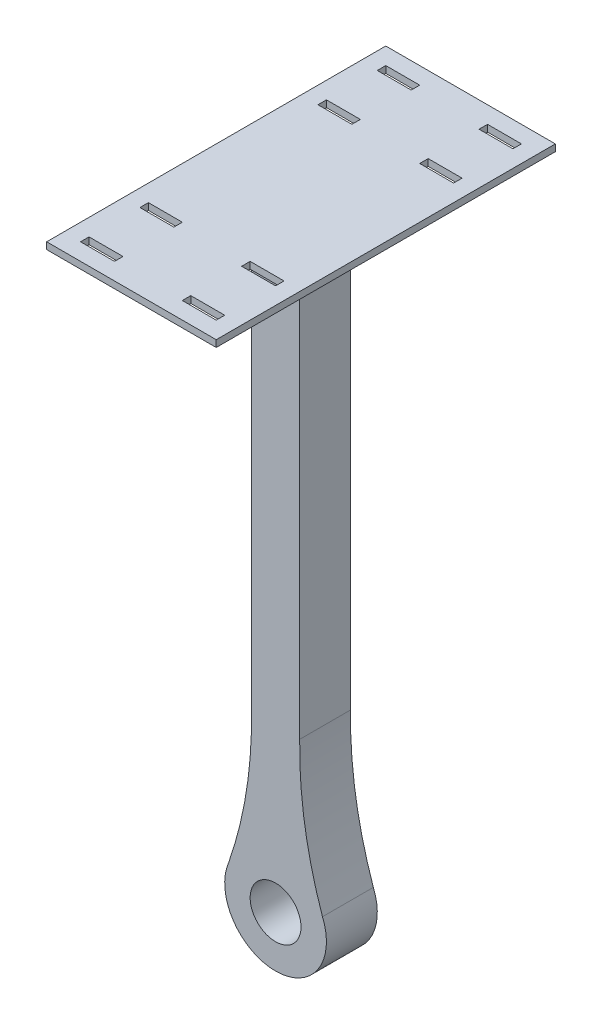
from build123d import *

# Parameters (mm, degrees)
SKETCH1_R           = 30
SKETCH1_R_2         = 15
BOSS_EXTRUDE1_DEPTH = 15
BOSS_EXTRUDE2_DEPTH = 30
SKETCH3_W           = 100
SKETCH3_H           = 200
BOSS_EXTRUDE3_DEPTH = 4
SKETCH4_W           = 20
SKETCH4_H           = 5
CUT_EXTRUDE1_DEPTH  = 4


with BuildPart() as part:
    # Sketch1 → Boss-Extrude1 (new body, symmetric)
    with BuildSketch(Plane.XY):
        Circle(SKETCH1_R)
        Circle(SKETCH1_R_2, mode=Mode.SUBTRACT)
    extrude(amount=BOSS_EXTRUDE1_DEPTH, both=True)

    # Sketch2 → Boss-Extrude2 (add)
    with BuildSketch(Plane.XY.offset(15)):
        with BuildLine():
            Line((14.241500135, 95.50219019), (14.241500135, 360))
            Line((14.241500135, 360), (-14.241500135, 360))
            Line((-14.241500135, 360), (-14.241500135, 95.50219019))
            add(Edge.make_bspline(
                [(-27.670395385, 11.590911061), (-13.495600511, 52.469413615), (-14.241500135, 95.50219019)],
                knots=[0, 0, 0, 1, 1, 1], degree=2))
            ThreePointArc((-27.670395385, 11.590911061), (0, 30), (27.670395385, 11.590911061))
            add(Edge.make_bspline(
                [(27.670395385, 11.590911061), (13.495600511, 52.469413615), (14.241500135, 95.50219019)],
                knots=[0, 0, 0, 1, 1, 1], degree=2))
        make_face()
    extrude(amount=-BOSS_EXTRUDE2_DEPTH)

    # Sketch3 → Boss-Extrude3 (add)
    with BuildSketch(Plane(origin=(0, 360, 0), x_dir=(1, 0, 0), z_dir=(0, 1, 0))):
        Rectangle(SKETCH3_W, SKETCH3_H)
    extrude(amount=-BOSS_EXTRUDE3_DEPTH)

    # Sketch4 → Cut-Extrude1 (cut)
    with BuildSketch(Plane.XZ.offset(-356)):
        with Locations((30, 87.5)):
            Rectangle(SKETCH4_W, SKETCH4_H)
        with Locations((-30, 87.5)):
            Rectangle(SKETCH4_W, SKETCH4_H)
        with Locations((-30, -87.5)):
            Rectangle(SKETCH4_W, SKETCH4_H)
        with Locations((30, -87.5)):
            Rectangle(SKETCH4_W, SKETCH4_H)
        with Locations((-30, 52.5)):
            Rectangle(SKETCH4_W, SKETCH4_H)
        with Locations((30, 52.5)):
            Rectangle(SKETCH4_W, SKETCH4_H)
        with Locations((30, -52.5)):
            Rectangle(SKETCH4_W, SKETCH4_H)
        with Locations((-30, -52.5)):
            Rectangle(SKETCH4_W, SKETCH4_H)
    extrude(amount=-CUT_EXTRUDE1_DEPTH, mode=Mode.SUBTRACT)


solid = part.part
